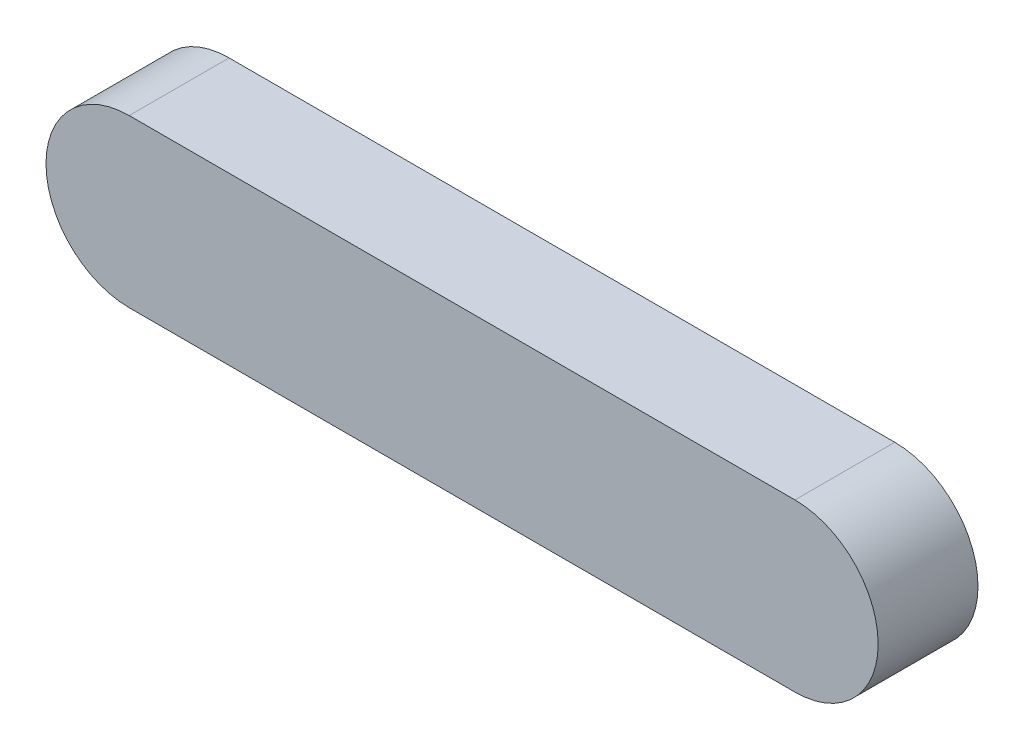
from build123d import *

# Parameters (mm, degrees)
BOSS_EXTRUDE1_DEPTH = 6


with BuildPart() as part:
    # Sketch1 → Boss-Extrude1 (new body)
    with BuildSketch(Plane.XY):
        with BuildLine():
            Line((0, 5), (40, 5))
            ThreePointArc((40, 5), (45, 0), (40, -5))
            Line((40, -5), (0, -5))
            ThreePointArc((0, -5), (-5, 0), (0, 5))
        make_face()
    extrude(amount=BOSS_EXTRUDE1_DEPTH)


solid = part.part
